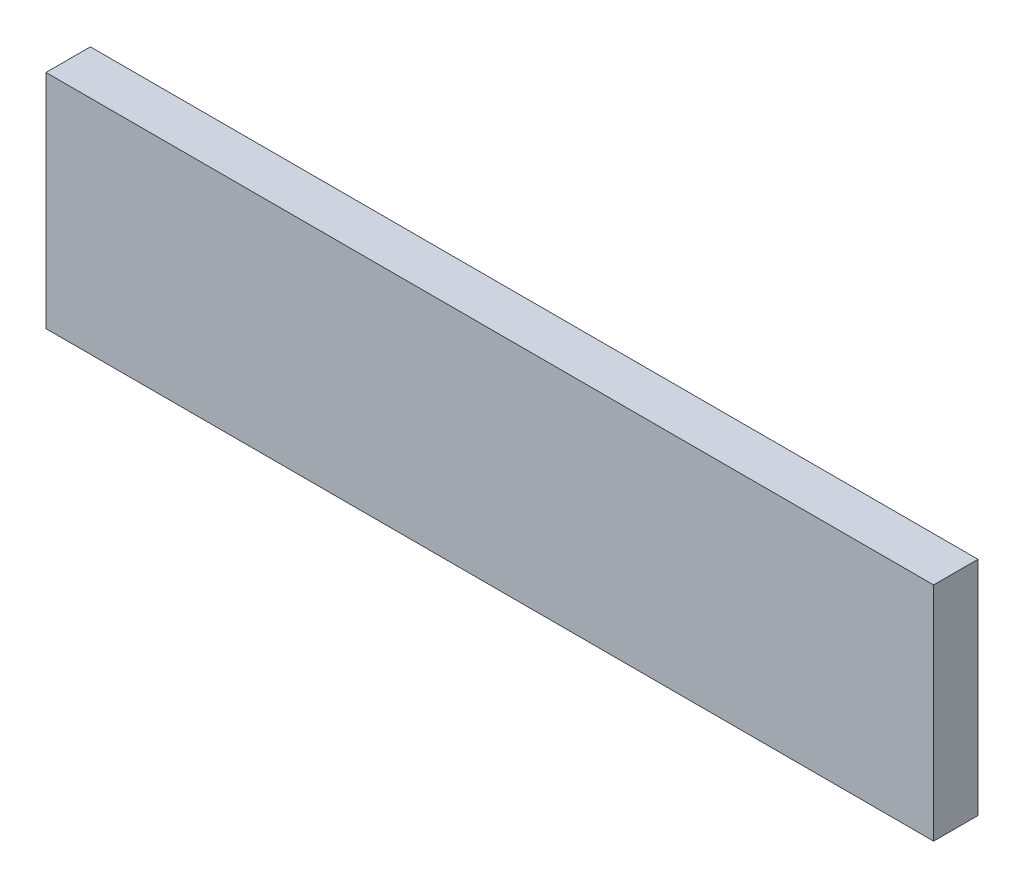
from build123d import *

# Parameters (mm, degrees)
SKETCH1_W           = 127
SKETCH1_H           = 31.75
BOSS_EXTRUDE1_DEPTH = 6.35


with BuildPart() as part:
    # Sketch1 → Boss-Extrude1 (new body)
    with BuildSketch(Plane.XY):
        Rectangle(SKETCH1_W, SKETCH1_H)
    extrude(amount=BOSS_EXTRUDE1_DEPTH)


solid = part.part
